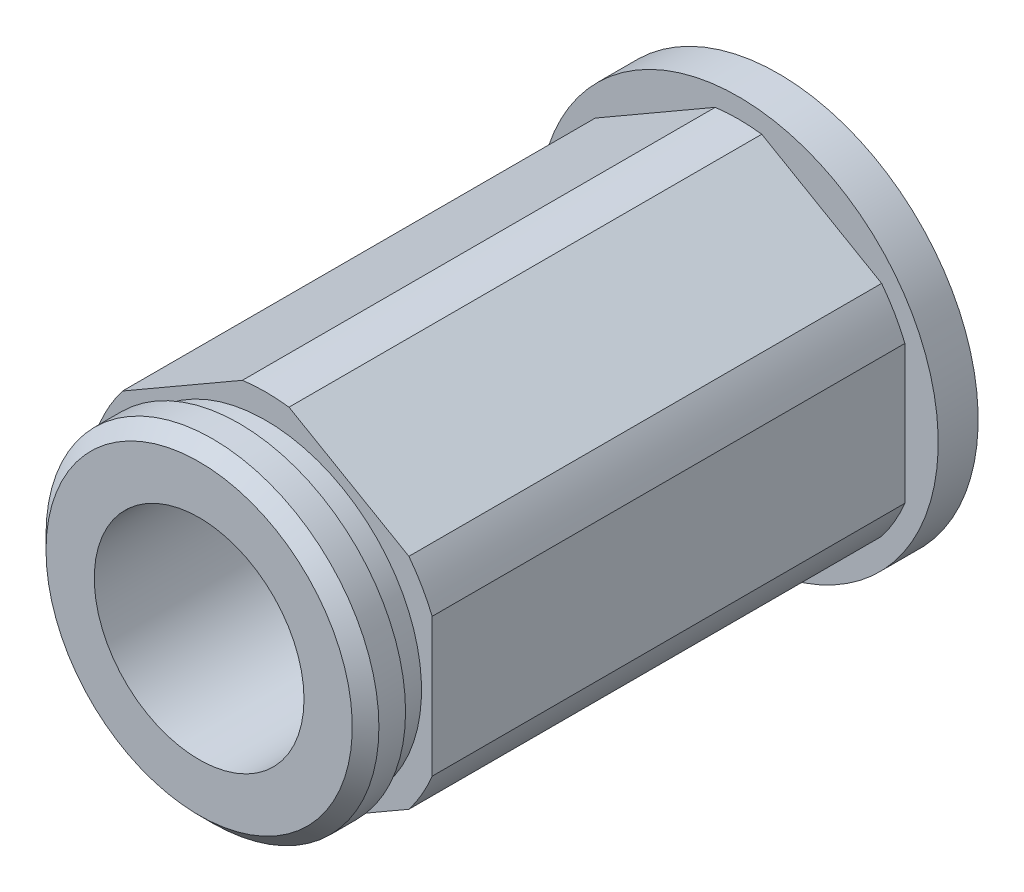
from build123d import *

# Parameters (mm, degrees)
SKETCH1_R               = 6.35
BASIC_ROD_DEPTH         = 9.779
BASIC_ROD_DEPTH_BACK    = 9.779
THEX_DEPTH              = 9.779
SKETCH2_R               = 4.0005
INTERNAL_CUT_DEPTH      = 13.319
INTERNAL_CUT_DEPTH_BACK = 10.779
SKETCH9_R               = 7.62
SKETCH9_R_2             = 4.0005
BOSS_EXTRUDE1_DEPTH     = 1.524


with BuildPart() as part:
    # Sketch1 → Basic Rod (new body, two sides)
    with BuildSketch(Plane.XY) as basic_rod_sk:
        Circle(SKETCH1_R)
    extrude(amount=BASIC_ROD_DEPTH)
    extrude(basic_rod_sk.sketch, amount=-BASIC_ROD_DEPTH_BACK)

    # Sketch8 → THex (add, symmetric)
    with BuildSketch(Plane.XY):
        with BuildLine():
            Line((-0.888411378, 6.819423871), (-5.461588622, 4.179098758))
            ThreePointArc((-5.461588622, 4.179098758), (-5.955700003, 3.438525), (-6.35, 2.640325113))
            Line((-6.35, 2.640325113), (-6.35, -2.640325113))
            ThreePointArc((-6.35, -2.640325113), (-5.955700003, -3.438525), (-5.461588622, -4.179098758))
            Line((-5.461588622, -4.179098758), (-0.888411378, -6.819423871))
            ThreePointArc((-0.888411378, -6.819423871), (0, -6.87705), (0.888411378, -6.819423871))
            Line((0.888411378, -6.819423871), (5.461588622, -4.179098758))
            ThreePointArc((5.461588622, -4.179098758), (5.955700003, -3.438525), (6.35, -2.640325113))
            Line((6.35, -2.640325113), (6.35, 2.640325113))
            ThreePointArc((6.35, 2.640325113), (5.955700003, 3.438525), (5.461588622, 4.179098758))
            Line((5.461588622, 4.179098758), (0.888411378, 6.819423871))
            ThreePointArc((0.888411378, 6.819423871), (0, 6.87705), (-0.888411378, 6.819423871))
        make_face()
    extrude(amount=THEX_DEPTH, both=True)

    # Sketch7 → 1stSnapRing (revolve)
    with BuildSketch(Plane(origin=(0, 0, 0), x_dir=(0, 0, -1), z_dir=(1, 0, 0))):
        Polygon((-9.779, 5.9436), (-10.795, 5.9436), (-10.795, 6.35), (-11.811, 6.35), (-12.319, 5.842), (-12.319, 0), (-9.779, 0), align=None)
    revolve(axis=Axis((0, 0, -38.2778), (0, 0, 1)))

    # Sketch2 → Internal Cut (cut, two sides)
    with BuildSketch(Plane.XY) as internal_cut_sk:
        Circle(SKETCH2_R)
    extrude(amount=INTERNAL_CUT_DEPTH, mode=Mode.SUBTRACT)
    extrude(internal_cut_sk.sketch, amount=-INTERNAL_CUT_DEPTH_BACK, mode=Mode.SUBTRACT)

    # Sketch9 → Boss-Extrude1 (add)
    with BuildSketch(Plane(origin=(0, 0, -9.779), x_dir=(-1, 0, 0), z_dir=(0, 0, -1))):
        Circle(SKETCH9_R)
        Circle(SKETCH9_R_2, mode=Mode.SUBTRACT)
    extrude(amount=-BOSS_EXTRUDE1_DEPTH)


solid = part.part
